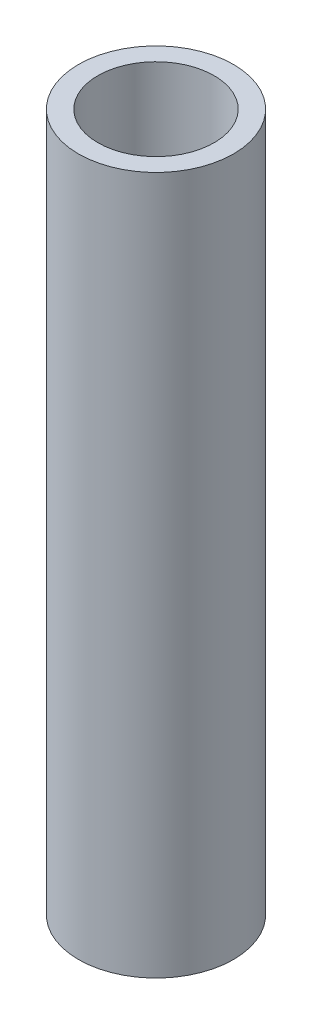
from build123d import *

# Parameters (mm, degrees)
SKETCH1_R           = 12.7
SKETCH1_R_2         = 9.525
BOSS_EXTRUDE2_DEPTH = 114.3


with BuildPart() as part:
    # Sketch1 → Boss-Extrude2 (new body)
    with BuildSketch(Plane(origin=(0, 0, 0), x_dir=(1, 0, 0), z_dir=(0, 1, 0))):
        Circle(SKETCH1_R)
        Circle(SKETCH1_R_2, mode=Mode.SUBTRACT)
    extrude(amount=BOSS_EXTRUDE2_DEPTH)


solid = part.part
